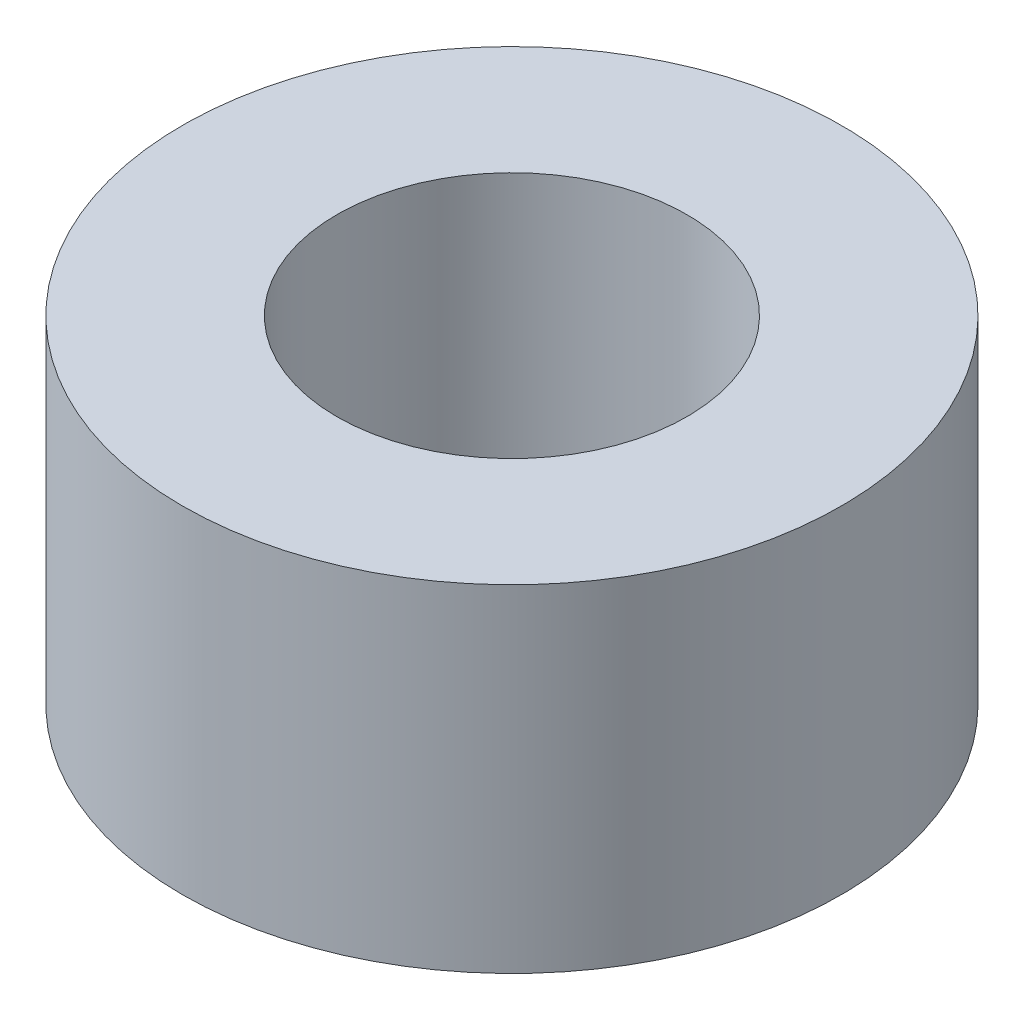
from build123d import *

# Parameters (mm, degrees)
SKETCH1_R           = 4.894584923
BOSS_EXTRUDE1_DEPTH = 5
SKETCH2_R           = 2.6
CUT_EXTRUDE1_DEPTH  = 6


with BuildPart() as part:
    # Sketch1 → Boss-Extrude1 (new body)
    with BuildSketch(Plane(origin=(0, 0, 0), x_dir=(1, 0, 0), z_dir=(0, 1, 0))):
        Circle(SKETCH1_R)
    extrude(amount=BOSS_EXTRUDE1_DEPTH)

    # Sketch2 → Cut-Extrude1 (cut, through all)
    with BuildSketch(Plane(origin=(0, 5, 0), x_dir=(1, 0, 0), z_dir=(0, 1, 0))):
        Circle(SKETCH2_R)
    extrude(amount=-CUT_EXTRUDE1_DEPTH, mode=Mode.SUBTRACT)


solid = part.part
